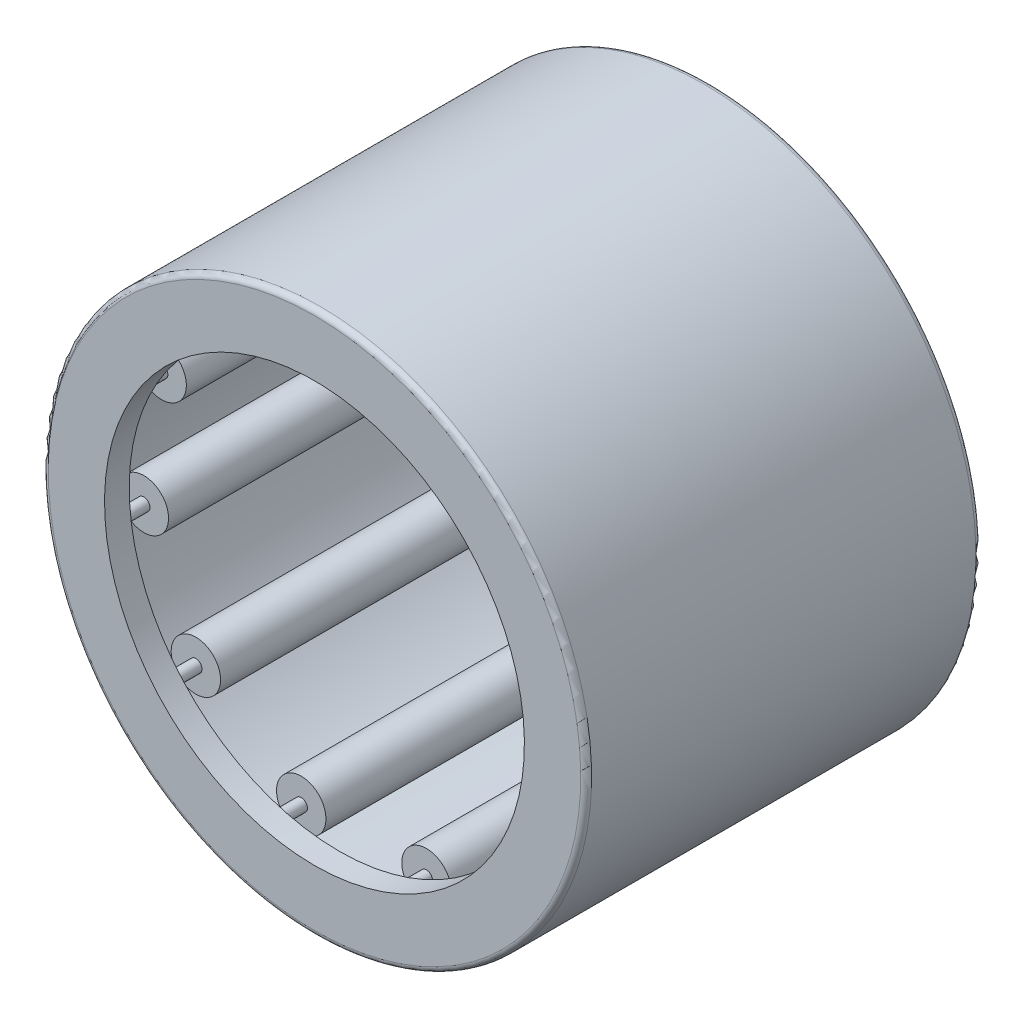
from build123d import *

# Parameters (mm, degrees)
SKETCH2_W         = 9.525
SKETCH2_H         = 0.5953125
SKETCH3_W         = 11.1125
SKETCH3_H         = 0.1984375
CIRPATTERN1_COUNT = 11
CIRPATTERN1_ANGLE = 327.272727273
FILLET1_R         = 0.174625


with BuildPart() as part:
    # Sketch1 → Revolve1 (revolve)
    with BuildSketch(Plane(origin=(0, 0, 0), x_dir=(0, 0, -1), z_dir=(1, 0, 0))):
        Polygon((-6.35, 8.73125), (6.35, 8.73125), (6.35, 6.746875), (5.55625, 6.746875), (5.55625, 7.9375), (-5.55625, 7.9375), (-5.55625, 6.746875), (-6.35, 6.746875), align=None)
    revolve(axis=Axis((0, 0, 6.35), (0, 0, -1)))

    # Fillet1
    fillet1_edges = [part.edges().sort_by_distance(p)[0] for p in [
        (0, -8.73125, 6.35),
        (0, -8.73125, -6.35),
    ]]
    fillet(fillet1_edges, radius=FILLET1_R)


with BuildPart() as body_2:
    # Sketch2 → Revolve2 (revolve)
    with BuildSketch(Plane(origin=(0, 0, 0), x_dir=(0, 0, -1), z_dir=(1, 0, 0))):
        with Locations((0, 7.63984375)):
            Rectangle(SKETCH2_W, SKETCH2_H)
    revolve(axis=Axis((0, 7.14375, 4.7625), (0, 0, -1)))


with BuildPart() as body_3:
    # Sketch3 → Revolve3 (revolve)
    with BuildSketch(Plane(origin=(0, 0, 0), x_dir=(0, 0, -1), z_dir=(1, 0, 0))):
        with Locations((0, 7.24296875)):
            Rectangle(SKETCH3_W, SKETCH3_H)
    revolve(axis=Axis((0, 7.14375, 5.55625), (0, 0, -1)))


with BuildPart() as cirpattern1_1:
    # CirPattern1: pattern copy
    add(body_2.part.rotate(Axis((0, 0, -6.35), (0, 0, 1)), 1 * CIRPATTERN1_ANGLE / (CIRPATTERN1_COUNT - 1)))


with BuildPart() as cirpattern1_2:
    # CirPattern1: pattern copy
    add(body_2.part.rotate(Axis((0, 0, -6.35), (0, 0, 1)), 2 * CIRPATTERN1_ANGLE / (CIRPATTERN1_COUNT - 1)))


with BuildPart() as cirpattern1_3:
    # CirPattern1: pattern copy
    add(body_2.part.rotate(Axis((0, 0, -6.35), (0, 0, 1)), 3 * CIRPATTERN1_ANGLE / (CIRPATTERN1_COUNT - 1)))


with BuildPart() as cirpattern1_4:
    # CirPattern1: pattern copy
    add(body_2.part.rotate(Axis((0, 0, -6.35), (0, 0, 1)), 4 * CIRPATTERN1_ANGLE / (CIRPATTERN1_COUNT - 1)))


with BuildPart() as cirpattern1_5:
    # CirPattern1: pattern copy
    add(body_2.part.rotate(Axis((0, 0, -6.35), (0, 0, 1)), 5 * CIRPATTERN1_ANGLE / (CIRPATTERN1_COUNT - 1)))


with BuildPart() as cirpattern1_6:
    # CirPattern1: pattern copy
    add(body_2.part.rotate(Axis((0, 0, -6.35), (0, 0, 1)), 6 * CIRPATTERN1_ANGLE / (CIRPATTERN1_COUNT - 1)))


with BuildPart() as cirpattern1_7:
    # CirPattern1: pattern copy
    add(body_2.part.rotate(Axis((0, 0, -6.35), (0, 0, 1)), 7 * CIRPATTERN1_ANGLE / (CIRPATTERN1_COUNT - 1)))


with BuildPart() as cirpattern1_8:
    # CirPattern1: pattern copy
    add(body_2.part.rotate(Axis((0, 0, -6.35), (0, 0, 1)), 8 * CIRPATTERN1_ANGLE / (CIRPATTERN1_COUNT - 1)))


with BuildPart() as cirpattern1_9:
    # CirPattern1: pattern copy
    add(body_2.part.rotate(Axis((0, 0, -6.35), (0, 0, 1)), 9 * CIRPATTERN1_ANGLE / (CIRPATTERN1_COUNT - 1)))


with BuildPart() as cirpattern1_10:
    # CirPattern1: pattern copy
    add(body_2.part.rotate(Axis((0, 0, -6.35), (0, 0, 1)), 10 * CIRPATTERN1_ANGLE / (CIRPATTERN1_COUNT - 1)))


with BuildPart() as cirpattern1_11:
    # CirPattern1: pattern copy
    add(body_3.part.rotate(Axis((0, 0, -6.35), (0, 0, 1)), 1 * CIRPATTERN1_ANGLE / (CIRPATTERN1_COUNT - 1)))


with BuildPart() as cirpattern1_12:
    # CirPattern1: pattern copy
    add(body_3.part.rotate(Axis((0, 0, -6.35), (0, 0, 1)), 2 * CIRPATTERN1_ANGLE / (CIRPATTERN1_COUNT - 1)))


with BuildPart() as cirpattern1_13:
    # CirPattern1: pattern copy
    add(body_3.part.rotate(Axis((0, 0, -6.35), (0, 0, 1)), 3 * CIRPATTERN1_ANGLE / (CIRPATTERN1_COUNT - 1)))


with BuildPart() as cirpattern1_14:
    # CirPattern1: pattern copy
    add(body_3.part.rotate(Axis((0, 0, -6.35), (0, 0, 1)), 4 * CIRPATTERN1_ANGLE / (CIRPATTERN1_COUNT - 1)))


with BuildPart() as cirpattern1_15:
    # CirPattern1: pattern copy
    add(body_3.part.rotate(Axis((0, 0, -6.35), (0, 0, 1)), 5 * CIRPATTERN1_ANGLE / (CIRPATTERN1_COUNT - 1)))


with BuildPart() as cirpattern1_16:
    # CirPattern1: pattern copy
    add(body_3.part.rotate(Axis((0, 0, -6.35), (0, 0, 1)), 6 * CIRPATTERN1_ANGLE / (CIRPATTERN1_COUNT - 1)))


with BuildPart() as cirpattern1_17:
    # CirPattern1: pattern copy
    add(body_3.part.rotate(Axis((0, 0, -6.35), (0, 0, 1)), 7 * CIRPATTERN1_ANGLE / (CIRPATTERN1_COUNT - 1)))


with BuildPart() as cirpattern1_18:
    # CirPattern1: pattern copy
    add(body_3.part.rotate(Axis((0, 0, -6.35), (0, 0, 1)), 8 * CIRPATTERN1_ANGLE / (CIRPATTERN1_COUNT - 1)))


with BuildPart() as cirpattern1_19:
    # CirPattern1: pattern copy
    add(body_3.part.rotate(Axis((0, 0, -6.35), (0, 0, 1)), 9 * CIRPATTERN1_ANGLE / (CIRPATTERN1_COUNT - 1)))


with BuildPart() as cirpattern1_20:
    # CirPattern1: pattern copy
    add(body_3.part.rotate(Axis((0, 0, -6.35), (0, 0, 1)), 10 * CIRPATTERN1_ANGLE / (CIRPATTERN1_COUNT - 1)))


solid = Compound([part.part, body_2.part, body_3.part, cirpattern1_1.part, cirpattern1_2.part, cirpattern1_3.part, cirpattern1_4.part, cirpattern1_5.part, cirpattern1_6.part, cirpattern1_7.part, cirpattern1_8.part, cirpattern1_9.part, cirpattern1_10.part, cirpattern1_11.part, cirpattern1_12.part, cirpattern1_13.part, cirpattern1_14.part, cirpattern1_15.part, cirpattern1_16.part, cirpattern1_17.part, cirpattern1_18.part, cirpattern1_19.part, cirpattern1_20.part])
